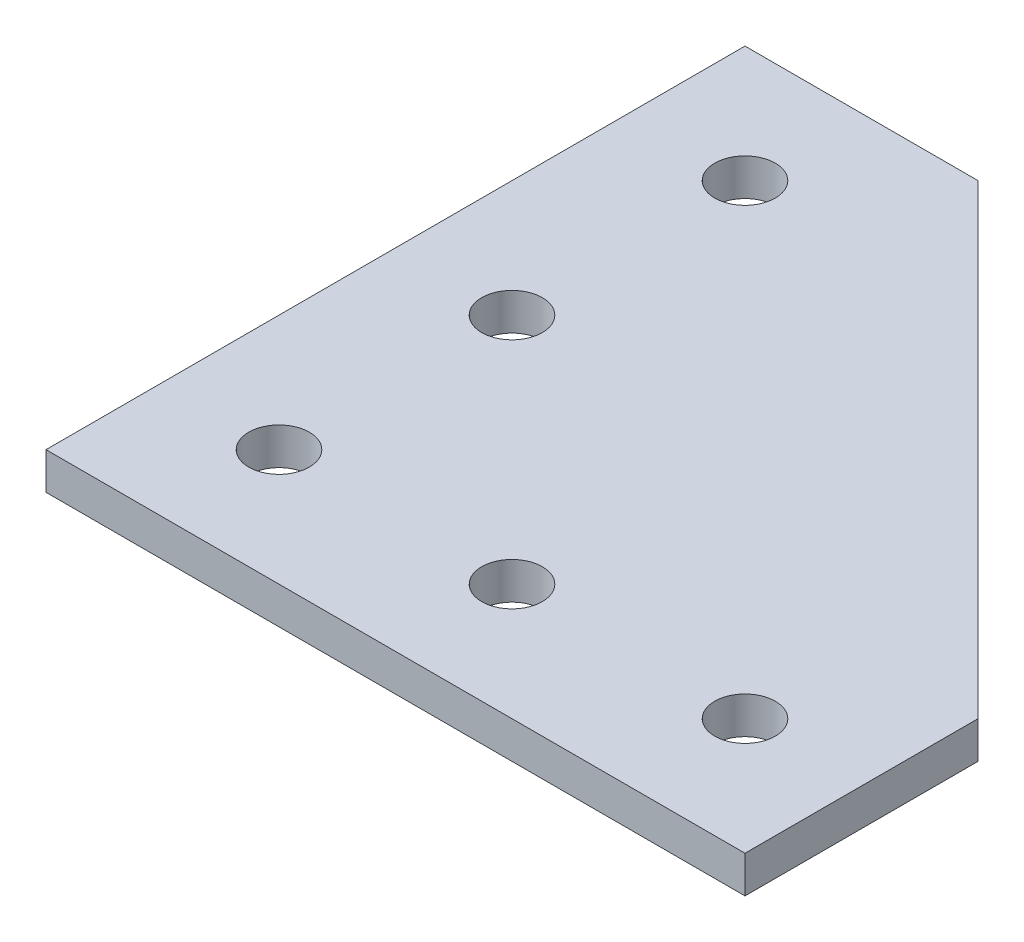
from build123d import *

# Parameters (mm, degrees)
SKETCH1_R           = 2.6
BOSS_EXTRUDE1_DEPTH = 3.175


with BuildPart() as part:
    # Sketch1 → Boss-Extrude1 (new body)
    with BuildSketch(Plane(origin=(0, 0, 0), x_dir=(1, 0, 0), z_dir=(0, 1, 0))):
        Polygon((60, 0), (60, 20), (20, 60), (0, 60), (0, 0), align=None)
        with Locations((50, 10)):
            Circle(SKETCH1_R, mode=Mode.SUBTRACT)
        with Locations((10, 50)):
            Circle(SKETCH1_R, mode=Mode.SUBTRACT)
        with Locations((30, 10)):
            Circle(SKETCH1_R, mode=Mode.SUBTRACT)
        with Locations((10, 10)):
            Circle(SKETCH1_R, mode=Mode.SUBTRACT)
        with Locations((10, 30)):
            Circle(SKETCH1_R, mode=Mode.SUBTRACT)
    extrude(amount=BOSS_EXTRUDE1_DEPTH)


solid = part.part
